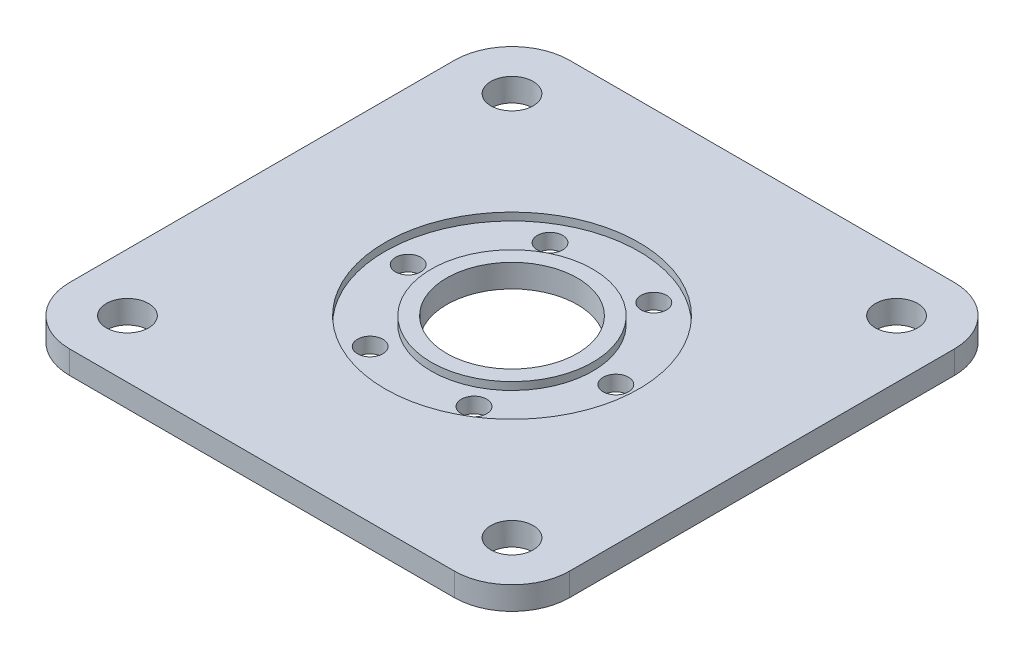
from build123d import *

# Parameters (mm, degrees)
SKETCH1_R                = 17
BOSS_EXTRUDE1_DEPTH      = 6
SKETCH2_R                = 33
SKETCH2_R_2              = 21
CUT_EXTRUDE1_DEPTH       = 2
SKETCH3_R                = 5.5
CUT_EXTRUDE2_DEPTH       = 1
CUT_EXTRUDE2_DEPTH_BACK  = 7
M6_CLEARANCE_HOLE1_D     = 6.6
M6_CLEARANCE_HOLE1_DEPTH = 4
CIRPATTERN1_COUNT        = 6


with BuildPart() as part:
    # Sketch1 → Boss-Extrude1 (new body)
    with BuildSketch(Plane(origin=(0, 0, 0), x_dir=(1, 0, 0), z_dir=(0, 1, 0))):
        with BuildLine():
            Line((-50, -65), (50, -65))
            ThreePointArc((50, -65), (60.606601718, -60.606601718), (65, -50))
            Line((65, -50), (65, 50))
            ThreePointArc((65, 50), (60.606601718, 60.606601718), (50, 65))
            Line((50, 65), (-50, 65))
            ThreePointArc((-50, 65), (-60.606601718, 60.606601718), (-65, 50))
            Line((-65, 50), (-65, -50))
            ThreePointArc((-65, -50), (-60.606601718, -60.606601718), (-50, -65))
        make_face()
        Circle(SKETCH1_R, mode=Mode.SUBTRACT)
    extrude(amount=BOSS_EXTRUDE1_DEPTH)

    # Sketch2 → Cut-Extrude1 (cut)
    with BuildSketch(Plane(origin=(0, 6, 0), x_dir=(1, 0, 0), z_dir=(0, 1, 0))):
        Circle(SKETCH2_R)
        Circle(SKETCH2_R_2, mode=Mode.SUBTRACT)
    extrude(amount=-CUT_EXTRUDE1_DEPTH, mode=Mode.SUBTRACT)

    # Sketch3 → Cut-Extrude2 (cut, two sides)
    with BuildSketch(Plane(origin=(0, 6, 0), x_dir=(1, 0, 0), z_dir=(0, 1, 0))) as cut_extrude2_sk:
        with Locations((-50, 50)):
            Circle(SKETCH3_R)
        with Locations((50, 50)):
            Circle(SKETCH3_R)
        with Locations((50, -50)):
            Circle(SKETCH3_R)
        with Locations((-50, -50)):
            Circle(SKETCH3_R)
    extrude(amount=CUT_EXTRUDE2_DEPTH, mode=Mode.SUBTRACT)
    extrude(cut_extrude2_sk.sketch, amount=-CUT_EXTRUDE2_DEPTH_BACK, mode=Mode.SUBTRACT)

    # M6 Clearance Hole1
    with Locations(Plane(origin=(-27, 4, 0), x_dir=(0, 0, 1), z_dir=(0, 1, 0))):
        with Locations((0, 0)):
            m6_clearance_hole1 = Hole(M6_CLEARANCE_HOLE1_D / 2, depth=M6_CLEARANCE_HOLE1_DEPTH)

    # CirPattern1: M6 Clearance Hole1 ×6 about axis
    cirpattern1_axis = Axis((0, 0, 0), (0, 1, 0))
    for i in range(1, CIRPATTERN1_COUNT):
        add(m6_clearance_hole1.rotate(cirpattern1_axis, i * 360 / CIRPATTERN1_COUNT), mode=Mode.SUBTRACT)


solid = part.part
